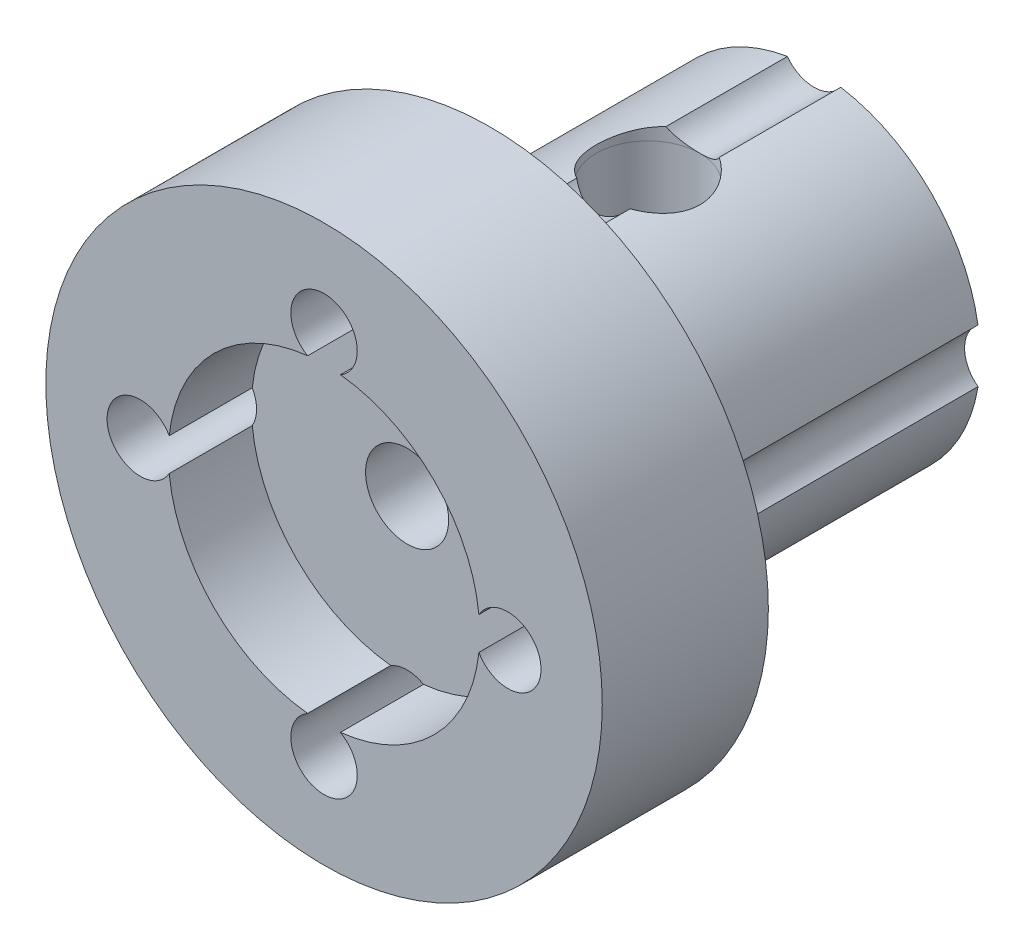
from build123d import *

# Parameters (mm, degrees)
SKIZZE1_R                       = 6.7
SKIZZE1_R_2                     = 3.75
SKIZZE1_R_3                     = 4
AUFSATZ_LINEAR_AUSTRAGEN1_DEPTH = 4
SKIZZE1_4_R                     = 4
SKIZZE1_4_R_2                   = 3.75
SKIZZE1_4_R_3                   = 1
AUFSATZ_LINEAR_AUSTRAGEN2_DEPTH = 7.8
SKIZZE1_6_R                     = 4
SKIZZE1_6_R_2                   = 1
AUFSATZ_LINEAR_AUSTRAGEN3_DEPTH = 2
M2_GEWINDEBOHRUNG1_D            = 1.6
M3_GEWINDEBOHRUNG1_D            = 2.5


with BuildPart() as part:
    # Skizze1 → Aufsatz-Linear austragen1 (new body)
    with BuildSketch(Plane.XY):
        Circle(SKIZZE1_R)
        Circle(SKIZZE1_R_2, mode=Mode.SUBTRACT)
        Circle(SKIZZE1_R_3)
        Circle(SKIZZE1_R_2, mode=Mode.SUBTRACT)
    extrude(amount=AUFSATZ_LINEAR_AUSTRAGEN1_DEPTH)

    # Skizze1_4 → Aufsatz-Linear austragen2 (add)
    with BuildSketch(Plane.XY):
        Circle(SKIZZE1_4_R)
        Circle(SKIZZE1_4_R_2, mode=Mode.SUBTRACT)
        Circle(SKIZZE1_4_R_2)
        Circle(SKIZZE1_4_R_3, mode=Mode.SUBTRACT)
    extrude(amount=-AUFSATZ_LINEAR_AUSTRAGEN2_DEPTH)

    # Skizze1_6 → Aufsatz-Linear austragen3 (add)
    with BuildSketch(Plane.XY):
        Circle(SKIZZE1_6_R)
        Circle(SKIZZE1_6_R_2, mode=Mode.SUBTRACT)
    extrude(amount=AUFSATZ_LINEAR_AUSTRAGEN3_DEPTH)

    # M2 Gewindebohrung1 (through all)
    with Locations(Plane.XY.offset(4)):
        with Locations((4.425, 0), (0, -4.425), (-4.425, 0), (0, 4.425)):
            Hole(M2_GEWINDEBOHRUNG1_D / 2)

    # M3 Gewindebohrung1 (through all)
    with Locations(Plane(origin=(0, 3.625, -3.8), x_dir=(1, 0, 0), z_dir=(0, 1, 0))):
        with Locations((0, 0)):
            Hole(M3_GEWINDEBOHRUNG1_D / 2)


solid = part.part
